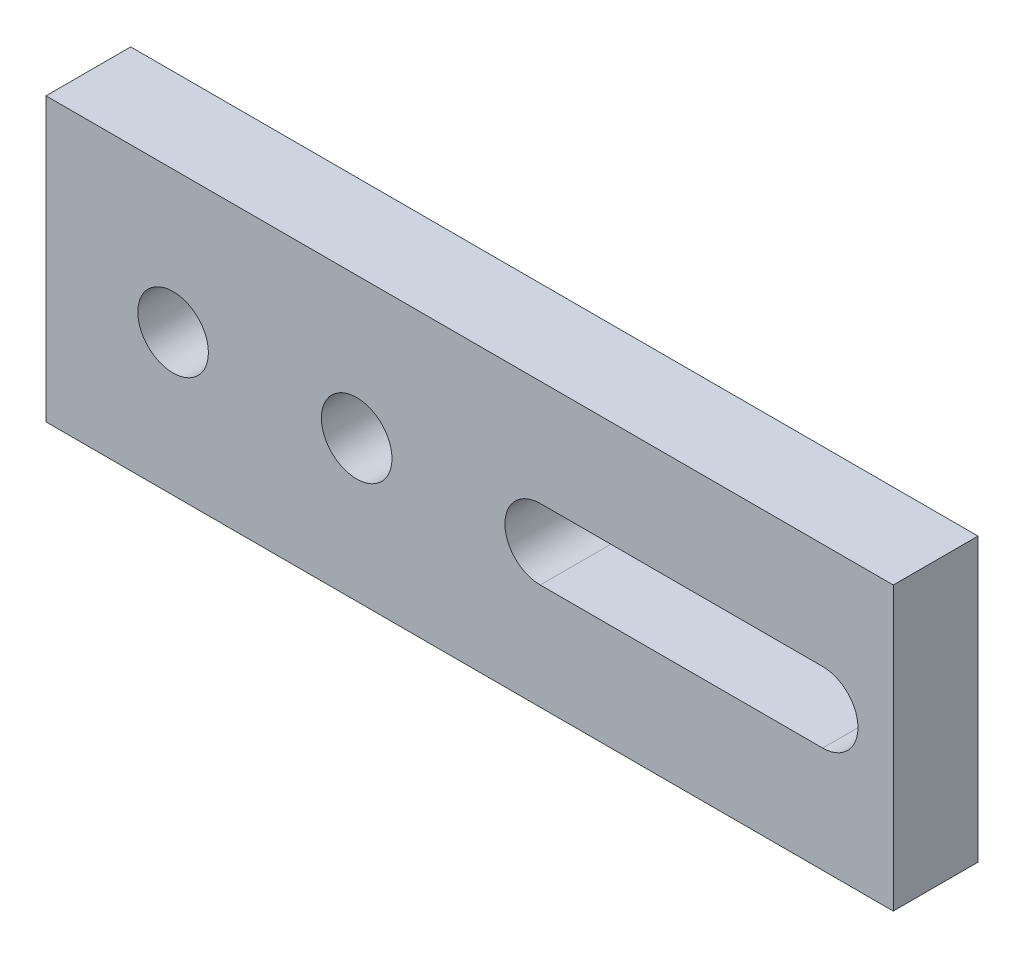
from build123d import *

# Parameters (mm, degrees)
SKETCH1_W           = 60
SKETCH1_H           = 20
SKETCH1_R           = 2.5
BOSS_EXTRUDE1_DEPTH = 6


with BuildPart() as part:
    # Sketch1 → Boss-Extrude1 (new body)
    with BuildSketch(Plane.XY):
        with Locations((30, 10)):
            Rectangle(SKETCH1_W, SKETCH1_H)
        with Locations((22, 10)):
            Circle(SKETCH1_R, mode=Mode.SUBTRACT)
        with Locations((9, 10)):
            Circle(SKETCH1_R, mode=Mode.SUBTRACT)
        with BuildLine():
            Line((35, 12.5), (55, 12.5))
            ThreePointArc((55, 12.5), (57.5, 10), (55, 7.5))
            Line((55, 7.5), (35, 7.5))
            ThreePointArc((35, 7.5), (32.5, 10), (35, 12.5))
        make_face(mode=Mode.SUBTRACT)
    extrude(amount=BOSS_EXTRUDE1_DEPTH)


solid = part.part
